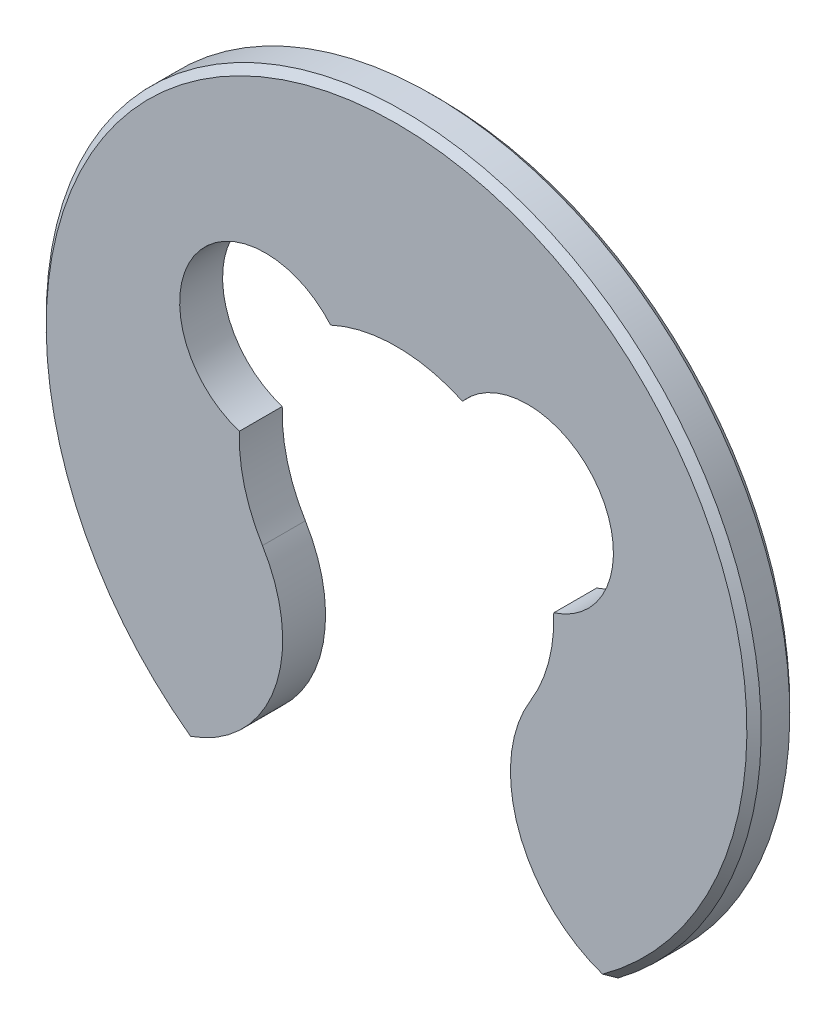
from build123d import *

# Parameters (mm, degrees)
EXTRUDE_1_DEPTH = 0.3
CHAMFER_1_SIZE  = 0.05


with BuildPart() as part:
    # 草图1 → 凸台-拉伸1 (new body)
    with BuildSketch(Plane.XY):
        with BuildLine():
            ThreePointArc((-1.099392644, 0.036548782), (-1.063477372, -0.281097632), (-0.937747349, -0.57500427))
            ThreePointArc((-0.937747349, -0.57500427), (-0.863262156, -1.427813797), (-1.5, -2))
            ThreePointArc((-1.5, -2), (0, 2.5), (1.5, -2))
            ThreePointArc((1.5, -2), (0.863262156, -1.427813797), (0.937747349, -0.57500427))
            ThreePointArc((0.937747349, -0.57500427), (1.063477372, -0.281097632), (1.099392644, 0.036548782))
            ThreePointArc((1.099392644, 0.036548782), (1.416666667, 0.939710357), (0.461213416, 0.998640168))
            ThreePointArc((0.461213416, 0.998640168), (0, 1.1), (-0.461213416, 0.998640168))
            ThreePointArc((-0.461213416, 0.998640168), (-1.416666667, 0.939710357), (-1.099392644, 0.036548782))
        make_face()
    extrude(amount=EXTRUDE_1_DEPTH)

    # 倒角1
    chamfer_1_edges = [part.edges().sort_by_distance(p)[0] for p in [
        (0, 2.5, 0.3),
        (0, 2.5, 0),
    ]]
    chamfer(chamfer_1_edges, length=CHAMFER_1_SIZE)


solid = part.part
